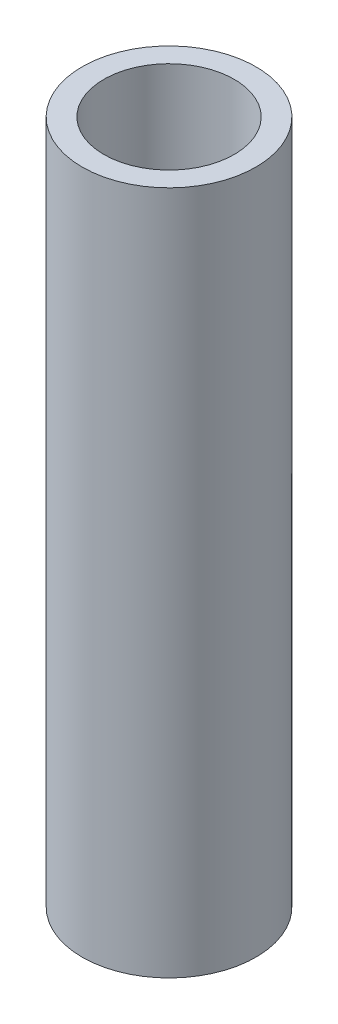
from build123d import *

# Parameters (mm, degrees)
SKETCH1_R           = 25.4
SKETCH1_R_2         = 19.05
BOSS_EXTRUDE1_DEPTH = 200


with BuildPart() as part:
    # Sketch1 → Boss-Extrude1 (new body)
    with BuildSketch(Plane(origin=(0, 0, 0), x_dir=(1, 0, 0), z_dir=(0, 1, 0))):
        with Locations(Location((0, 0, 0), (0, 0, 270))):  # turned: the seam where the file's is
            Circle(SKETCH1_R)
        with Locations(Location((0, 0, 0), (0, 0, 270))):  # turned: the seam where the file's is
            Circle(SKETCH1_R_2, mode=Mode.SUBTRACT)
    extrude(amount=BOSS_EXTRUDE1_DEPTH)


solid = part.part
